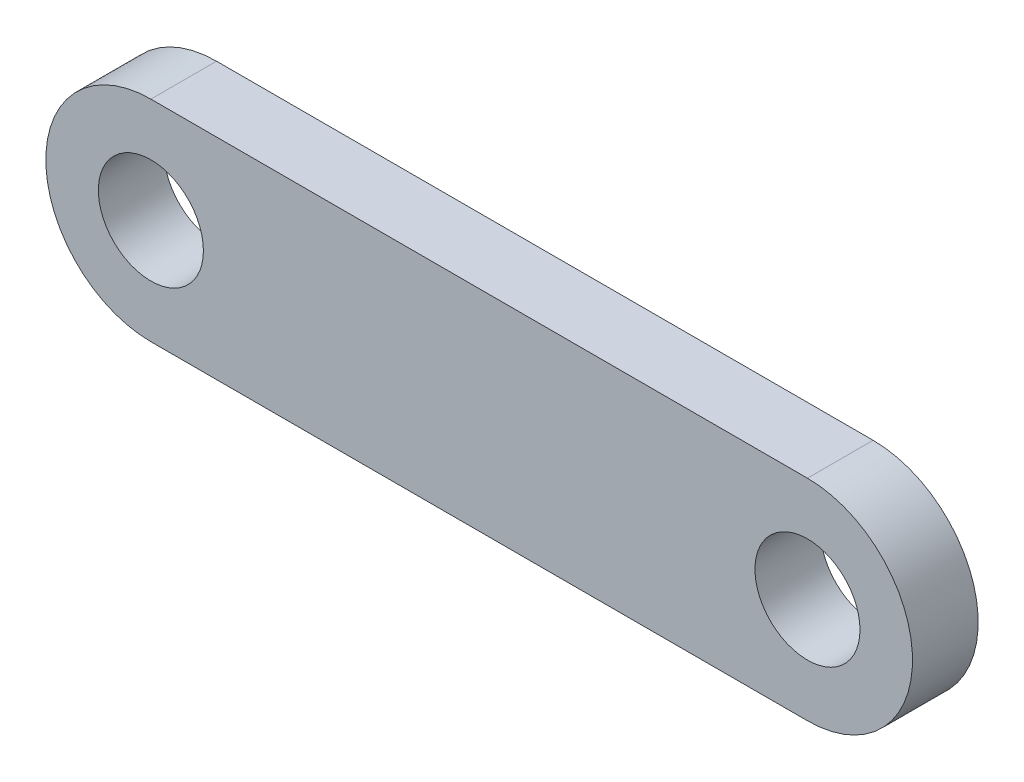
from build123d import *

# Parameters (mm, degrees)
SKETCH1_R           = 4
BOSS_EXTRUDE1_DEPTH = 5


with BuildPart() as part:
    # Sketch1 → Boss-Extrude1 (new body)
    with BuildSketch(Plane.XY):
        with BuildLine():
            Line((0, 8), (50, 8))
            ThreePointArc((50, 8), (58, 0), (50, -8))
            Line((50, -8), (0, -8))
            ThreePointArc((0, -8), (-8, 0), (0, 8))
        make_face()
        Circle(SKETCH1_R, mode=Mode.SUBTRACT)
        with Locations((50, 0)):
            Circle(SKETCH1_R, mode=Mode.SUBTRACT)
    extrude(amount=-BOSS_EXTRUDE1_DEPTH)


solid = part.part
